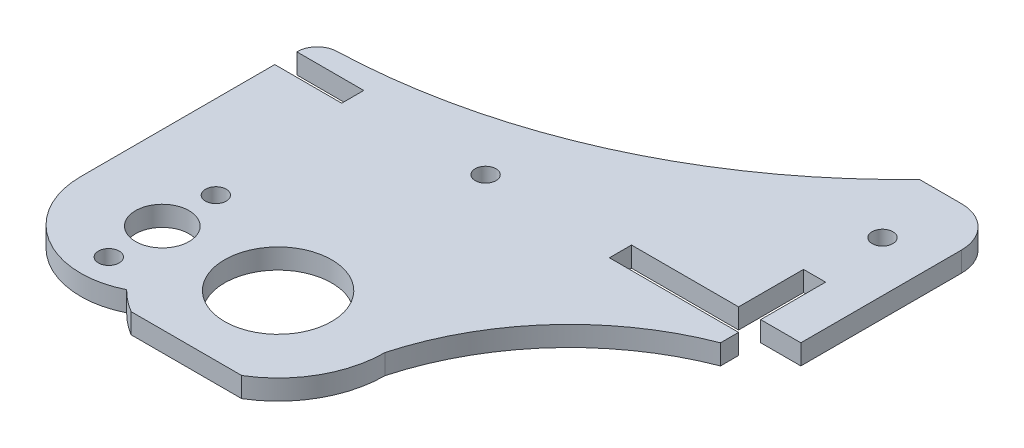
from build123d import *

# Parameters (mm, degrees)
CROQUIS1_R               = 1.55
CROQUIS1_R_2             = 4
SALIENTE_EXTRUIR10_DEPTH = 3
CROQUIS2_R               = 8
CROQUIS2_R_2             = 1.55
CORTAR_EXTRUIR1_DEPTH    = 3
CROQUIS3_OUTSIDE_W       = 98.706
CROQUIS3_OUTSIDE_H       = 99.406
CROQUIS3_OUTSIDE_R       = 4
CROQUIS3_OUTSIDE_R_2     = 8
CROQUIS3_OUTSIDE_R_3     = 1.55
CORTAR_EXTRUIR2_DEPTH    = 3
REDONDEO1_R              = 6
REDONDEO2_R              = 3


with BuildPart() as part:
    # Croquis1 → Saliente-Extruir10 (new body)
    with BuildSketch(Plane(origin=(0, 0, 0), x_dir=(1, 0, 0), z_dir=(0, 1, 0))):
        Polygon((0, 0), (0, 38.7), (10, 38.7), (10, 42), (0, 42), (0, 72), (69.3, 72), (75.3, 72), (75.3, 52), (75.3, 42), (69.3, 42), (69.3, 51.7), (66, 51.7), (66, 42), (50, 42), (50, 38.7), (69.3, 38.7), (69.3, 0), (69.3, -4), (0, -4), align=None)
        with Locations((30, 40.2)):
            Circle(CROQUIS1_R, mode=Mode.SUBTRACT)
        with Locations((67.8, 61.7)):
            Circle(CROQUIS1_R, mode=Mode.SUBTRACT)
        with Locations((12.5, 9.4)):
            Circle(CROQUIS1_R_2, mode=Mode.SUBTRACT)
    extrude(amount=SALIENTE_EXTRUIR10_DEPTH)

    # Croquis2 → Cortar-Extruir1 (cut)
    with BuildSketch(Plane(origin=(0, 3, 0), x_dir=(1, 0, 0), z_dir=(0, 1, 0))):
        with Locations((29.5, 9.7)):
            Circle(CROQUIS2_R)
        with Locations((12.5, 17.4)):
            Circle(CROQUIS2_R_2)
        with Locations((12.5, 1.4)):
            Circle(CROQUIS2_R_2)
    extrude(amount=-CORTAR_EXTRUIR1_DEPTH, mode=Mode.SUBTRACT)

    # Croquis3 outside → Cortar-Extruir2 (cut)
    with BuildSketch(Plane(origin=(0, 3, 0), x_dir=(1, 0, 0), z_dir=(0, 1, 0))):
        with Locations((37.65, 34)):
            Rectangle(CROQUIS3_OUTSIDE_W, CROQUIS3_OUTSIDE_H)
        with BuildLine():
            Line((75.3, 72), (63, 72))
            ThreePointArc((63, 72), (34.270978976, 52.034382388), (0, 45))
            Line((0, 45), (0, 42))
            Line((0, 42), (10, 42))
            Line((10, 42), (10, 38.7))
            Line((10, 38.7), (0, 38.7))
            Line((0, 38.7), (0, 9.7))
            ThreePointArc((0, 9.7), (5.916961411, -0.92608126), (18.066176471, -1.492304477))
            ThreePointArc((18.066176471, -1.492304477), (19.571107199, -2.84659666), (21.235013612, -4))
            Line((21.235013612, -4), (37.764986388, -4))
            ThreePointArc((37.764986388, -4), (43.432691452, 1.833608903), (45.5, 9.7))
            ThreePointArc((45.5, 9.7), (54.274410069, 25.678480622), (69.3, 36))
            Line((69.3, 36), (69.3, 38.7))
            Line((69.3, 38.7), (50, 38.7))
            Line((50, 38.7), (50, 42))
            Line((50, 42), (66, 42))
            Line((66, 42), (66, 51.7))
            Line((66, 51.7), (69.3, 51.7))
            Line((69.3, 51.7), (69.3, 42))
            Line((69.3, 42), (75.3, 42))
            Line((75.3, 42), (75.3, 72))
        make_face(mode=Mode.SUBTRACT)
        with Locations((12.5, 9.4)):
            Circle(CROQUIS3_OUTSIDE_R)
        with Locations((29.5, 9.7)):
            Circle(CROQUIS3_OUTSIDE_R_2)
        with Locations((30, 40.2)):
            Circle(CROQUIS3_OUTSIDE_R_3)
        with Locations((67.8, 61.7)):
            Circle(CROQUIS3_OUTSIDE_R_3)
    extrude(amount=-CORTAR_EXTRUIR2_DEPTH, mode=Mode.SUBTRACT)

    # Redondeo1
    redondeo1_edges = [part.edges().sort_by_distance(p)[0] for p in [
        (75.3, 1.5, -72),
    ]]
    fillet(redondeo1_edges, radius=REDONDEO1_R)

    # Redondeo2
    redondeo2_edges = [part.edges().sort_by_distance(p)[0] for p in [
        (0, 1.5, -45),
    ]]
    fillet(redondeo2_edges, radius=REDONDEO2_R)


solid = part.part
